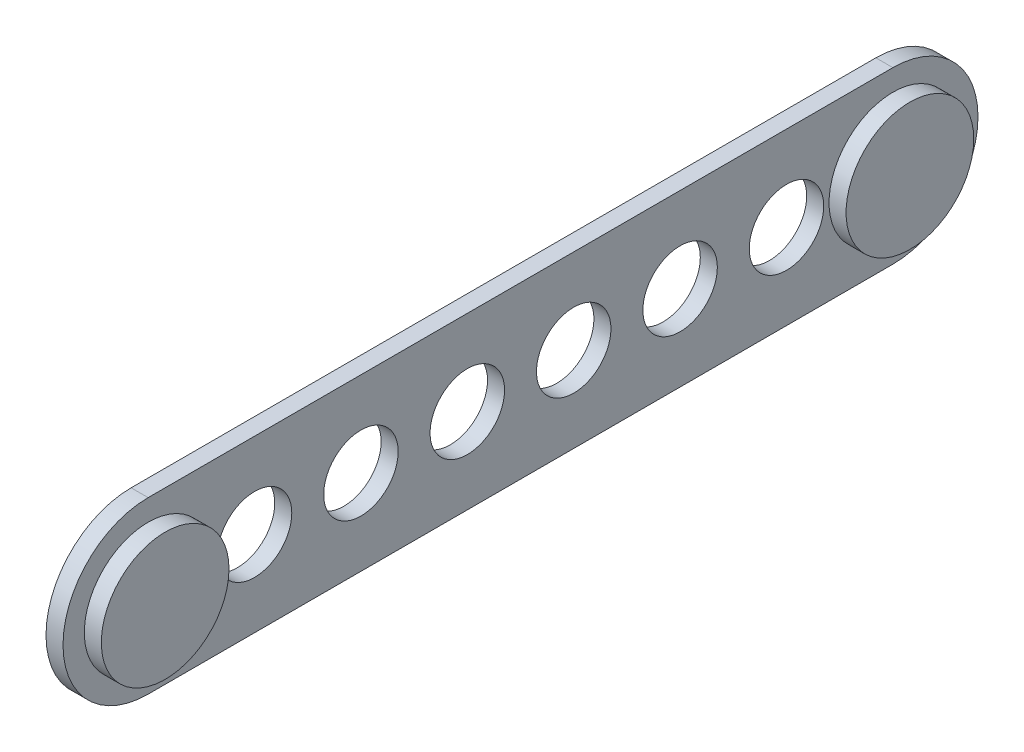
from build123d import *

# Parameters (mm, degrees)
BOSS_EXTRUDE1_DEPTH = 4.064
SKETCH2_R           = 15.24
BOSS_EXTRUDE2_DEPTH = 4.064
SKETCH3_R           = 8.89
CUT_EXTRUDE1_DEPTH  = 5.064
LPATTERN1_COUNT     = 6
LPATTERN1_PITCH     = 25.4


with BuildPart() as part:
    # Sketch1 → Boss-Extrude1 (new body)
    with BuildSketch(Plane(origin=(0, 0, 0), x_dir=(0, 0, -1), z_dir=(1, 0, 0))):
        with BuildLine():
            Line((0, 20.32), (177.8, 20.32))
            ThreePointArc((177.8, 20.32), (198.12, 0), (177.8, -20.32))
            Line((177.8, -20.32), (0, -20.32))
            ThreePointArc((0, -20.32), (-20.32, 0), (0, 20.32))
        make_face()
    extrude(amount=BOSS_EXTRUDE1_DEPTH)

    # Sketch2 → Boss-Extrude2 (add)
    with BuildSketch(Plane(origin=(4.064, 0, 0), x_dir=(0, 0, -1), z_dir=(1, 0, 0))):
        Circle(SKETCH2_R)
        with Locations((177.8, 0)):
            Circle(SKETCH2_R)
    extrude(amount=BOSS_EXTRUDE2_DEPTH)

    # Sketch3 → Cut-Extrude1 (cut, through all)
    with BuildSketch(Plane(origin=(4.064, 0, 0), x_dir=(0, 0, -1), z_dir=(1, 0, 0))):
        with Locations((25.4, 0)):
            Circle(SKETCH3_R)
    cut_extrude1 = extrude(amount=-CUT_EXTRUDE1_DEPTH, mode=Mode.SUBTRACT)

    # LPattern1: Cut-Extrude1 ×6
    with Locations(*[(0, 0, -i * LPATTERN1_PITCH) for i in range(1, LPATTERN1_COUNT)]):
        add(cut_extrude1, mode=Mode.SUBTRACT)


solid = part.part
